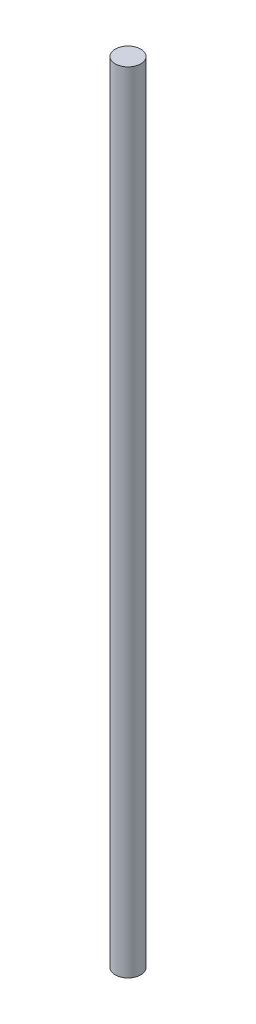
from build123d import *

# Parameters (mm, degrees)
SKETCH1_R           = 6
BOSS_EXTRUDE1_DEPTH = 370


with BuildPart() as part:
    # Sketch1 → Boss-Extrude1 (new body)
    with BuildSketch(Plane(origin=(0, 0, 0), x_dir=(1, 0, 0), z_dir=(0, 1, 0))):
        Circle(SKETCH1_R)
    extrude(amount=BOSS_EXTRUDE1_DEPTH)


solid = part.part
